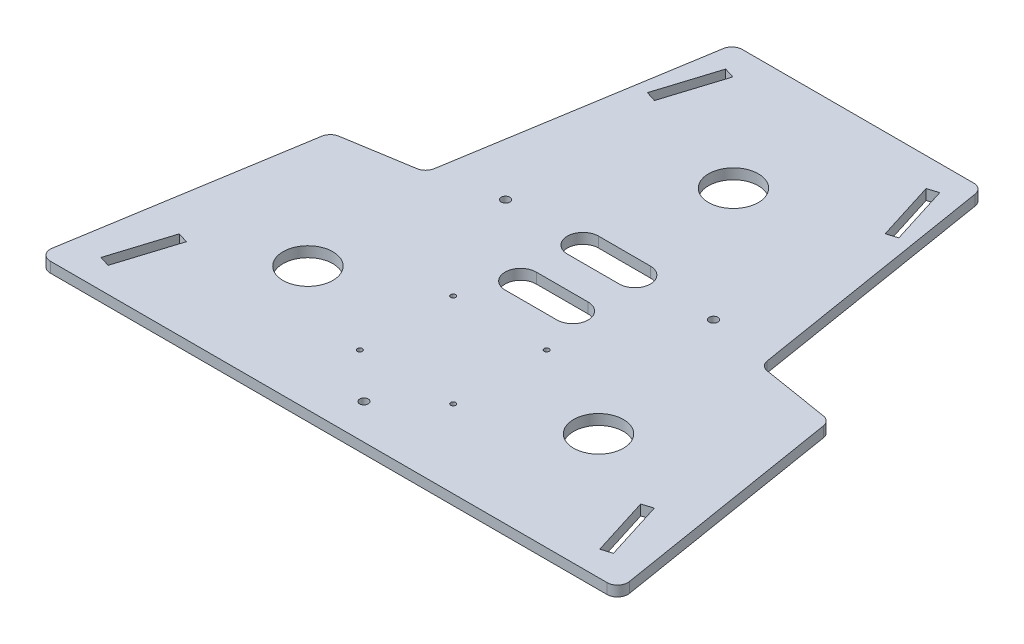
from build123d import *

# Parameters (mm, degrees)
SKETCH1_R           = 12
SKETCH1_R_2         = 1.2
SKETCH1_R_3         = 2.075
BOSS_EXTRUDE1_DEPTH = 5
CUT_EXTRUDE1_DEPTH  = 5


with BuildPart() as part:
    # Sketch1 → Boss-Extrude1 (new body)
    with BuildSketch(Plane(origin=(0, 0, 0), x_dir=(1, 0, 0), z_dir=(0, 1, 0))):
        with BuildLine():
            Line((-134.118891506, 0), (134.118891506, 0))
            ThreePointArc((134.118891506, 0), (137.928249972, 1.76136015), (139.053747558, 5.804484769))
            Line((139.053747558, 5.804484769), (120.84297072, 117.512705691))
            ThreePointArc((120.84297072, 117.512705691), (119.443648574, 120.243754828), (116.712599437, 121.643076974))
            Line((116.712599437, 121.643076974), (84.336583334, 126.921044874))
            ThreePointArc((84.336583334, 126.921044874), (81.605534197, 128.32036702), (80.206212051, 131.051416157))
            Line((80.206212051, 131.051416157), (60.683956749, 250.804484769))
            ThreePointArc((60.683956749, 250.804484769), (58.987740546, 253.809358466), (55.749100697, 255))
            Line((55.749100697, 255), (-55.749100697, 255))
            ThreePointArc((-55.749100697, 255), (-58.987740546, 253.809358466), (-60.683956749, 250.804484769))
            Line((-60.683956749, 250.804484769), (-80.206212051, 131.051416157))
            ThreePointArc((-80.206212051, 131.051416157), (-81.605534197, 128.32036702), (-84.336583334, 126.921044874))
            Line((-84.336583334, 126.921044874), (-116.712599437, 121.643076974))
            ThreePointArc((-116.712599437, 121.643076974), (-119.443648574, 120.243754828), (-120.84297072, 117.512705691))
            Line((-120.84297072, 117.512705691), (-139.053747558, 5.804484769))
            ThreePointArc((-139.053747558, 5.804484769), (-137.928249972, 1.76136015), (-134.118891506, 0))
        make_face()
        with Locations((0, 195)):
            Circle(SKETCH1_R, mode=Mode.SUBTRACT)
        with Locations((-70, 60)):
            Circle(SKETCH1_R, mode=Mode.SUBTRACT)
        with Locations((70, 60)):
            Circle(SKETCH1_R, mode=Mode.SUBTRACT)
        with Locations((-22.5, 82.5)):
            Circle(SKETCH1_R_2, mode=Mode.SUBTRACT)
        with Locations((22.5, 82.5)):
            Circle(SKETCH1_R_2, mode=Mode.SUBTRACT)
        with Locations((22.5, 37.5)):
            Circle(SKETCH1_R_2, mode=Mode.SUBTRACT)
        with Locations((-22.5, 37.5)):
            Circle(SKETCH1_R_2, mode=Mode.SUBTRACT)
        with Locations((-50.091827035, 135.325391796)):
            Circle(SKETCH1_R_3, mode=Mode.SUBTRACT)
        with Locations((50.091827035, 135.325391796)):
            Circle(SKETCH1_R_3, mode=Mode.SUBTRACT)
        with Locations((0, 17)):
            Circle(SKETCH1_R_3, mode=Mode.SUBTRACT)
        with BuildLine():
            Line((12.5, 127.5), (-12.5, 127.5))
            ThreePointArc((-12.5, 127.5), (-20, 135), (-12.5, 142.5))
            Line((-12.5, 142.5), (12.5, 142.5))
            ThreePointArc((12.5, 142.5), (20, 135), (12.5, 127.5))
        make_face(mode=Mode.SUBTRACT)
        with BuildLine():
            Line((12.5, 97.5), (-12.5, 97.5))
            ThreePointArc((-12.5, 97.5), (-20, 105), (-12.5, 112.5))
            Line((-12.5, 112.5), (12.5, 112.5))
            ThreePointArc((12.5, 112.5), (20, 105), (12.5, 97.5))
        make_face(mode=Mode.SUBTRACT)
    extrude(amount=BOSS_EXTRUDE1_DEPTH)

    # Sketch2 → Cut-Extrude1 (cut)
    with BuildSketch(Plane(origin=(0, 5, 0), x_dir=(1, 0, 0), z_dir=(0, 1, 0))):
        Polygon((-60.578994825, 214.111244254), (-51.568858582, 242.831053531), (-46.559589522, 241.259518139), (-55.569725765, 212.539708863), align=None)
        Polygon((-118.431141418, 12.168946469), (-109.421005175, 40.888755746), (-114.430274235, 42.460291137), (-123.440410478, 13.740481861), align=None)
        Polygon((123.440410478, 13.740481861), (114.430274235, 42.460291137), (109.421005175, 40.888755746), (118.431141418, 12.168946469), align=None)
        Polygon((55.569725765, 212.539708863), (46.559589522, 241.259518139), (51.568858582, 242.831053531), (60.578994825, 214.111244254), align=None)
    extrude(amount=-CUT_EXTRUDE1_DEPTH, mode=Mode.SUBTRACT)


solid = part.part
